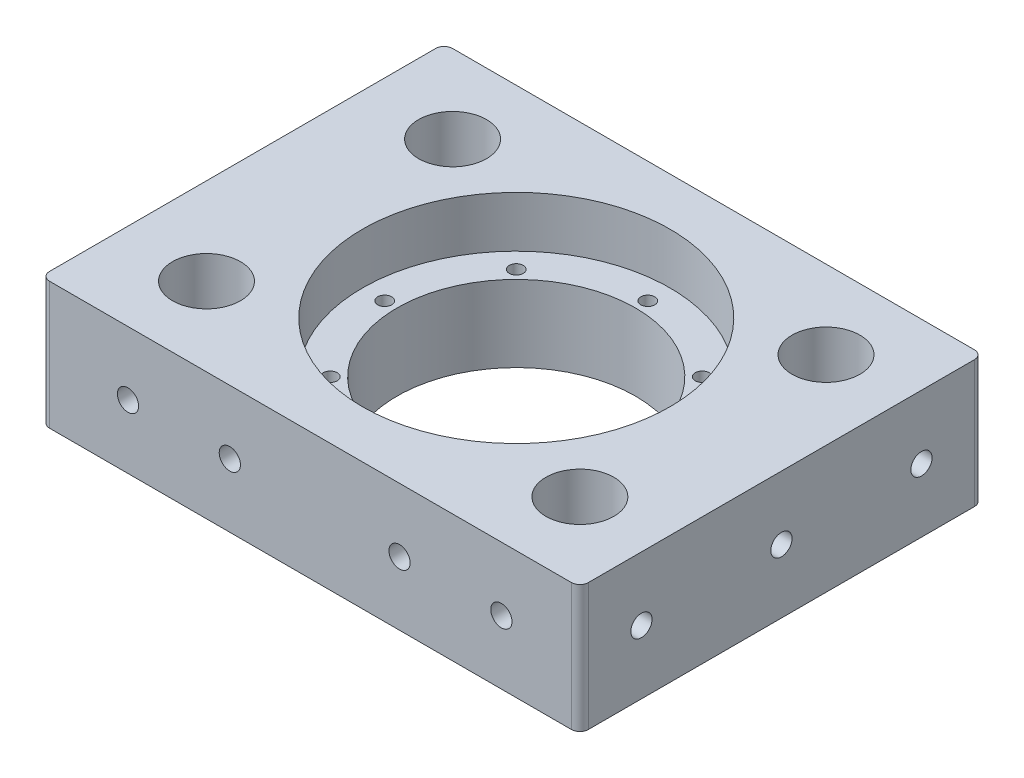
from build123d import *

# Parameters (mm, degrees)
SKETCH2_W                  = 125
SKETCH2_H                  = 95
SKETCH2_R                  = 28.1
SKETCH2_R_2                = 8
BOSS_EXTRUDE1_DEPTH        = 30
SKETCH10_R                 = 36.25
CUT_EXTRUDE3_DEPTH         = 12
M4X0_7_TAPPED_HOLE1_D      = 3.3
M6X1_0_TAPPED_HOLE1_D      = 5
M6X1_0_TAPPED_HOLE1_DEPTH  = 15
M6X1_0_TAPPED_HOLE1_TIP    = 1.502151548
SKETCH19_W                 = 95
SKETCH19_H                 = 30
BOSS_EXTRUDE3_DEPTH        = 2
M6X1_0_TAPPED_HOLE2_D      = 5
M6X1_0_TAPPED_HOLE2_DEPTH  = 11
M6X1_0_TAPPED_HOLE2_TIP    = 1.502151548
CIRPATTERN1_COUNT          = 2
CIRPATTERN1_ANGLE          = 45
M6X1_0_TAPPED_HOLE5_REACH  = 120.681
M6X1_0_TAPPED_HOLE5_BORE_R = 2.5
FILLET1_R                  = 2


with BuildPart() as part:
    # Sketch2 → Boss-Extrude1 (new body)
    with BuildSketch(Plane(origin=(0, 0, 0), x_dir=(1, 0, 0), z_dir=(0, 1, 0))):
        Rectangle(SKETCH2_W, SKETCH2_H)
        with Locations(Location((0, 0, 0), (0, 0, 270))):
            Circle(SKETCH2_R, mode=Mode.SUBTRACT)
        with Locations(Location((44, 29, 0), (0, 0, 270))):
            Circle(SKETCH2_R_2, mode=Mode.SUBTRACT)
        with Locations(Location((44, -29, 0), (0, 0, 270))):
            Circle(SKETCH2_R_2, mode=Mode.SUBTRACT)
        with Locations(Location((-44, -29, 0), (0, 0, 270))):
            Circle(SKETCH2_R_2, mode=Mode.SUBTRACT)
        with Locations(Location((-44, 29, 0), (0, 0, 270))):
            Circle(SKETCH2_R_2, mode=Mode.SUBTRACT)
    extrude(amount=BOSS_EXTRUDE1_DEPTH)

    # Sketch10 → Cut-Extrude3 (cut)
    with BuildSketch(Plane(origin=(0, 30, 0), x_dir=(1, 0, 0), z_dir=(0, 1, 0))):
        with Locations(Location((0, 0, 0), (0, 0, 270))):
            Circle(SKETCH10_R)
    extrude(amount=-CUT_EXTRUDE3_DEPTH, mode=Mode.SUBTRACT)

    # M4x0.7 Tapped Hole1 (through all)
    with Locations(Plane(origin=(0, 18, 0), x_dir=(1, 0, 0), z_dir=(0, 1, 0))):
        with Locations((0, 31), (31, 0), (0, -31), (-31, 0)):
            m4x0_7_tapped_hole1 = Hole(M4X0_7_TAPPED_HOLE1_D / 2)

    # M6x1.0 Tapped Hole1
    with Locations(Plane.XY.offset(47.5)):
        with Locations((-20, 15), (20, 15)):
            Hole(M6X1_0_TAPPED_HOLE1_D / 2, depth=M6X1_0_TAPPED_HOLE1_DEPTH)
            with Locations((0, 0, -(M6X1_0_TAPPED_HOLE1_DEPTH + M6X1_0_TAPPED_HOLE1_TIP / 2))):  # 118° drill point
                Cone(0, M6X1_0_TAPPED_HOLE1_D / 2, M6X1_0_TAPPED_HOLE1_TIP, mode=Mode.SUBTRACT)

    # Sketch19 → Boss-Extrude3 (add)
    with BuildSketch(Plane.ZY.offset(62.5)):
        with Locations((0, 15)):
            Rectangle(SKETCH19_W, SKETCH19_H)
    extrude(amount=BOSS_EXTRUDE3_DEPTH)

    # M6x1.0 Tapped Hole2
    with Locations(Plane(origin=(62.5, 0, 0), x_dir=(0, 0, 1), z_dir=(1, 0, 0))):
        with Locations((33, -15), (0, -15), (-33, -15)):
            Hole(M6X1_0_TAPPED_HOLE2_D / 2, depth=M6X1_0_TAPPED_HOLE2_DEPTH)
            with Locations((0, 0, -(M6X1_0_TAPPED_HOLE2_DEPTH + M6X1_0_TAPPED_HOLE2_TIP / 2))):  # 118° drill point
                Cone(0, M6X1_0_TAPPED_HOLE2_D / 2, M6X1_0_TAPPED_HOLE2_TIP, mode=Mode.SUBTRACT)

    # CirPattern1: M4x0.7 Tapped Hole1 ×2 about axis
    cirpattern1_axis = Axis((0, 0, 0), (0, -1, 0))
    for i in range(1, CIRPATTERN1_COUNT):
        add(m4x0_7_tapped_hole1.rotate(cirpattern1_axis, i * CIRPATTERN1_ANGLE / (CIRPATTERN1_COUNT - 1)), mode=Mode.SUBTRACT)

    # M6x1.0 Tapped Hole5 bore → M6x1.0 Tapped Hole5 (cut, up to next)
    with BuildSketch(Plane.XY.offset(47.5), mode=Mode.PRIVATE) as m6x1_0_tapped_hole5_sk1:
        with Locations((44, 15)):
            Circle(M6X1_0_TAPPED_HOLE5_BORE_R)
    m6x1_0_tapped_hole5_tool1 = extrude(m6x1_0_tapped_hole5_sk1.sketch, amount=-M6X1_0_TAPPED_HOLE5_REACH, mode=Mode.PRIVATE) & part.part
    # M6x1.0 Tapped Hole5 bore → M6x1.0 Tapped Hole5 (cut, up to next)
    with BuildSketch(Plane.XY.offset(47.5), mode=Mode.PRIVATE) as m6x1_0_tapped_hole5_sk2:
        with Locations((-44, 15)):
            Circle(M6X1_0_TAPPED_HOLE5_BORE_R)
    m6x1_0_tapped_hole5_tool2 = extrude(m6x1_0_tapped_hole5_sk2.sketch, amount=-M6X1_0_TAPPED_HOLE5_REACH, mode=Mode.PRIVATE) & part.part
    m6x1_0_tapped_hole5_1 = m6x1_0_tapped_hole5_tool1.solids().sort_by_distance((44, 15, 47.5))[0]
    add(m6x1_0_tapped_hole5_1, mode=Mode.SUBTRACT)
    m6x1_0_tapped_hole5_2 = m6x1_0_tapped_hole5_tool2.solids().sort_by_distance((-44, 15, 47.5))[0]
    add(m6x1_0_tapped_hole5_2, mode=Mode.SUBTRACT)
    m6x1_0_tapped_hole5 = m6x1_0_tapped_hole5_1 + m6x1_0_tapped_hole5_2  # M6x1.0 Tapped Hole5 as one shape, for the pattern or mirror that repeats it

    # Fillet1
    fillet1_edges = [part.edges().sort_by_distance(p)[0] for p in [
        (62.5, 15, 47.5),
        (62.5, 15, -47.5),
        (-64.5, 15, -47.5),
        (-64.5, 15, 47.5),
    ]]
    fillet(fillet1_edges, radius=FILLET1_R)

    # Mirror1: M6x1.0 Tapped Hole5 across plane
    add(m6x1_0_tapped_hole5.mirror(Plane.XY), mode=Mode.SUBTRACT)


solid = part.part
